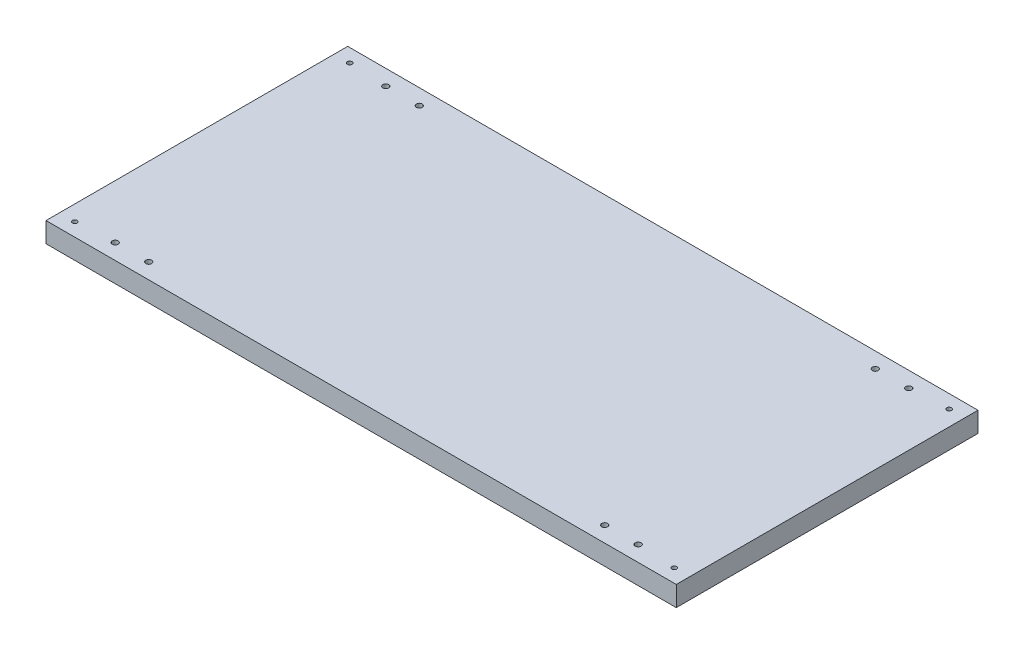
from build123d import *

# Parameters (mm, degrees)
SKETCH2_W           = 470
SKETCH2_H           = 225
SKETCH2_R           = 1.75
BOSS_EXTRUDE1_DEPTH = 15
SKETCH3_R           = 2.2
CUT_EXTRUDE1_DEPTH  = 16
SKETCH4_R           = 2.2
CUT_EXTRUDE2_DEPTH  = 16


with BuildPart() as part:
    # Sketch2 → Boss-Extrude1 (new body)
    with BuildSketch(Plane(origin=(0, 0, 0), x_dir=(1, 0, 0), z_dir=(0, 1, 0))):
        Rectangle(SKETCH2_W, SKETCH2_H)
        with Locations((223.5, 102.5)):
            Circle(SKETCH2_R, mode=Mode.SUBTRACT)
        with Locations((223.5, -102.5)):
            Circle(SKETCH2_R, mode=Mode.SUBTRACT)
        with Locations((-223.5, -102.5)):
            Circle(SKETCH2_R, mode=Mode.SUBTRACT)
        with Locations((-223.5, 102.5)):
            Circle(SKETCH2_R, mode=Mode.SUBTRACT)
    extrude(amount=BOSS_EXTRUDE1_DEPTH)

    # Sketch3 → Cut-Extrude1 (cut, through all)
    with BuildSketch(Plane(origin=(0, 15, 0), x_dir=(1, 0, 0), z_dir=(0, 1, 0))):
        with Locations((-195, 100.9)):
            Circle(SKETCH3_R)
        with Locations((-170, 100.9)):
            Circle(SKETCH3_R)
        with Locations((195, 100.9)):
            Circle(SKETCH3_R)
        with Locations((170.000001969, 100.909922977)):
            Circle(SKETCH3_R)
    extrude(amount=-CUT_EXTRUDE1_DEPTH, mode=Mode.SUBTRACT)

    # Sketch4 → Cut-Extrude2 (cut, through all)
    with BuildSketch(Plane(origin=(0, 15, 0), x_dir=(1, 0, 0), z_dir=(0, 1, 0))):
        with Locations((-195, -100.9)):
            Circle(SKETCH4_R)
        with Locations((195, -100.9)):
            Circle(SKETCH4_R)
        with Locations((-170, -100.9)):
            Circle(SKETCH4_R)
        with Locations((170, -100.9)):
            Circle(SKETCH4_R)
    extrude(amount=-CUT_EXTRUDE2_DEPTH, mode=Mode.SUBTRACT)


solid = part.part
